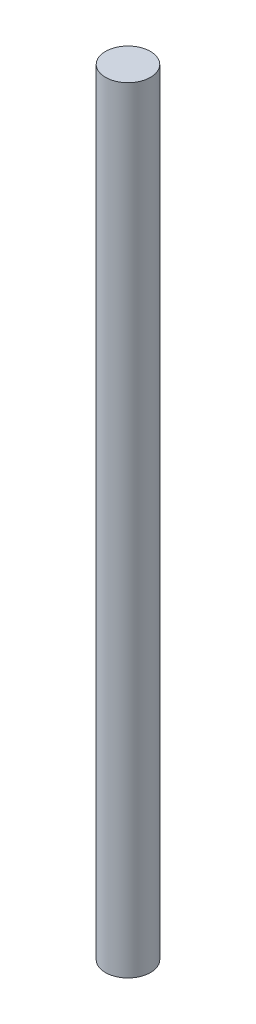
from build123d import *

# Parameters (mm, degrees)
SKETCH1_R           = 1.45
BOSS_EXTRUDE1_DEPTH = 50


with BuildPart() as part:
    # Sketch1 → Boss-Extrude1 (new body)
    with BuildSketch(Plane(origin=(0, 0, 0), x_dir=(1, 0, 0), z_dir=(0, 1, 0))):
        Circle(SKETCH1_R)
    extrude(amount=BOSS_EXTRUDE1_DEPTH)


solid = part.part
